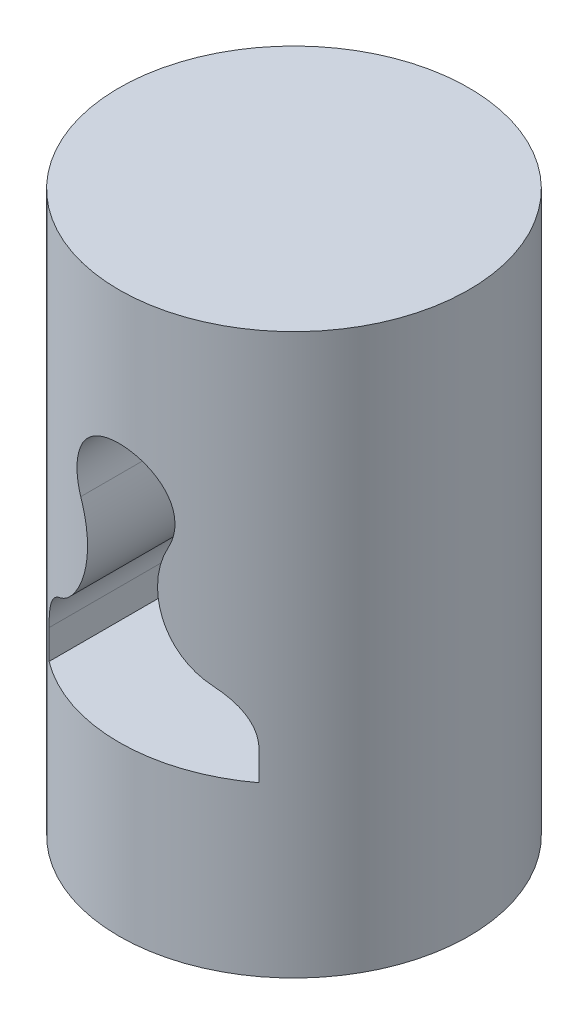
from build123d import *

# Parameters (mm, degrees)
SKETCH2_R               = 12.5
BOSS_EXTRUDE1_DEPTH     = 20
CUT_EXTRUDE1_DEPTH      = 13.5
CUT_EXTRUDE1_DEPTH_BACK = 13.5
SKETCH4_R               = 3
CUT_EXTRUDE2_DEPTH      = 3


with BuildPart() as part:
    # Sketch2 → Boss-Extrude1 (new body, symmetric)
    with BuildSketch(Plane(origin=(0, 0, 0), x_dir=(1, 0, 0), z_dir=(0, 1, 0))):
        Circle(SKETCH2_R)
    extrude(amount=BOSS_EXTRUDE1_DEPTH, both=True)

    # Sketch3 → Cut-Extrude1 (cut, two sides)
    with BuildSketch(Plane.XY) as cut_extrude1_sk:
        with BuildLine():
            Line((-7.5, -8), (7.5, -8))
            Line((7.5, -8), (7.5, -5.902894725))
            ThreePointArc((7.5, -5.902894725), (6.964101615, -3.902894725), (5.5, -2.43879311))
            ThreePointArc((5.5, -2.43879311), (2.754189416, 1.029452854), (3.131578947, 5.436921852))
            ThreePointArc((3.131578947, 5.436921852), (0, 10.5), (-3.131578947, 5.436921852))
            ThreePointArc((-3.131578947, 5.436921852), (-2.754189416, 1.029452854), (-5.5, -2.43879311))
            ThreePointArc((-5.5, -2.43879311), (-6.964101615, -3.902894725), (-7.5, -5.902894725))
            Line((-7.5, -5.902894725), (-7.5, -8))
        make_face()
    extrude(amount=CUT_EXTRUDE1_DEPTH, mode=Mode.SUBTRACT)
    extrude(cut_extrude1_sk.sketch, amount=-CUT_EXTRUDE1_DEPTH_BACK, mode=Mode.SUBTRACT)

    # Sketch4 → Cut-Extrude2 (cut)
    with BuildSketch(Plane(origin=(0, -20, 0), x_dir=(-1, 0, 0), z_dir=(0, -1, 0))):
        Circle(SKETCH4_R)
    extrude(amount=-CUT_EXTRUDE2_DEPTH, mode=Mode.SUBTRACT)


solid = part.part
